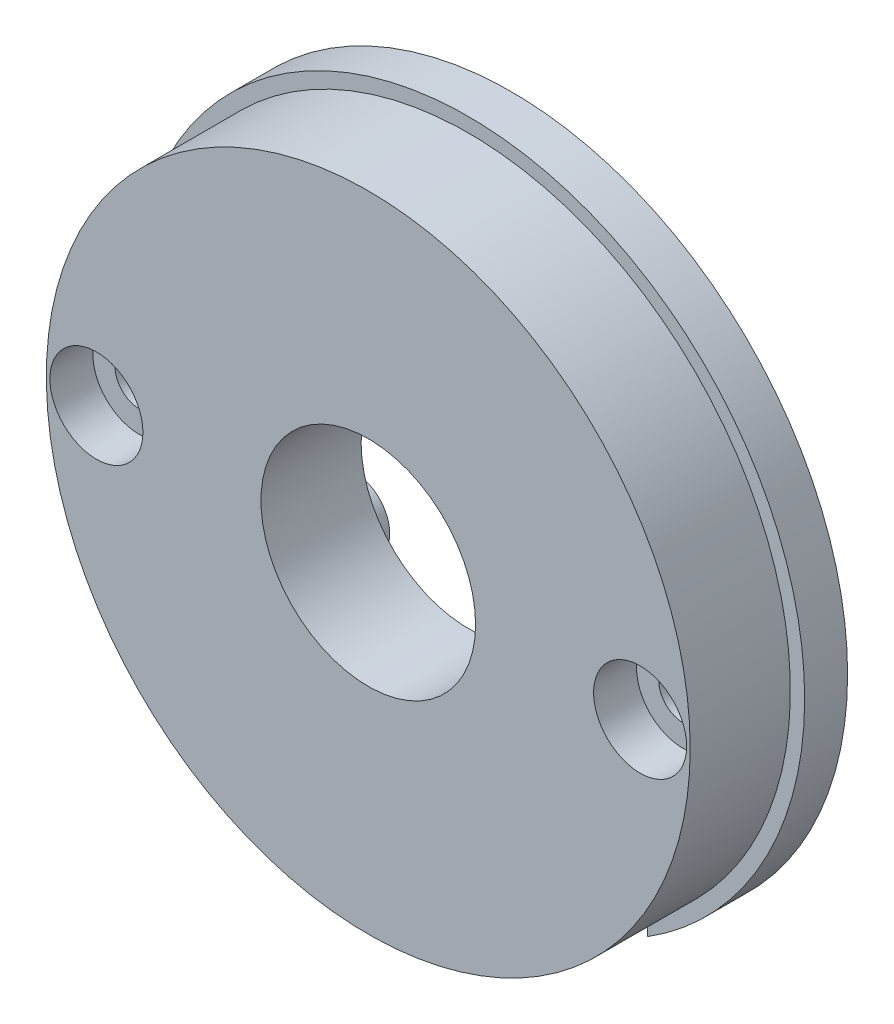
from build123d import *

# Parameters (mm, degrees)
SKETCH_5_R                   = 22.5
EXTRUDE_2_DEPTH              = 10
HOLE_WIZARD_M3_1_D           = 3.4
HOLE_WIZARD_M3_1_CBORE_D     = 6.5
HOLE_WIZARD_M3_1_CBORE_DEPTH = 3
SKETCH_12_W                  = 25
SKETCH_12_H                  = 40
CUT_EXTRUDE_1_DEPTH          = 3
EXTRUDE_3_DEPTH              = 1
SKETCH_14_R                  = 1.75
CUT_EXTRUDE_2_DEPTH          = 3
MIRROR_2_COPY_1_DEPTH        = 1
MIRROR_2_COPY_2_SKETCH_R     = 1.75
MIRROR_2_COPY_2_DEPTH        = 3
SKETCH_16_R                  = 7.5
CUT_EXTRUDE_3_DEPTH          = 11
EXTRUDE_4_DEPTH              = 3


with BuildPart() as part:
    # ｽｹｯﾁ5 → ﾎﾞｽ - 押し出し2 (new body)
    with BuildSketch(Plane.XY):
        Circle(SKETCH_5_R)
    extrude(amount=EXTRUDE_2_DEPTH)

    # M3 穴付きねじ用座ぐり穴1 (through all)
    with Locations(Plane.XY.offset(10)):
        with Locations((19, 0), (-19, 0)):
            CounterBoreHole(HOLE_WIZARD_M3_1_D / 2, HOLE_WIZARD_M3_1_CBORE_D / 2, HOLE_WIZARD_M3_1_CBORE_DEPTH)

    # ｽｹｯﾁ12 → ｶｯﾄ - 押し出し1 (cut)
    with BuildSketch(Plane(origin=(0, 0, 0), x_dir=(-1, 0, 0), z_dir=(0, 0, -1))):
        with Locations((0, -2.5)):
            Rectangle(SKETCH_12_W, SKETCH_12_H)
    extrude(amount=-CUT_EXTRUDE_1_DEPTH, mode=Mode.SUBTRACT)

    # ｽｹｯﾁ13 → ﾎﾞｽ - 押し出し3 (add)
    with BuildSketch(Plane(origin=(0, 0, 3), x_dir=(-1, 0, 0), z_dir=(0, 0, -1))):
        with BuildLine():
            Line((-12.5, 3), (-9, 3))
            ThreePointArc((-9, 3), (-6.5, 5.5), (-9, 8))
            Line((-9, 8), (-12.5, 8))
            Line((-12.5, 8), (-12.5, 3))
        make_face()
    extrude_3 = extrude(amount=EXTRUDE_3_DEPTH)

    # ｽｹｯﾁ14 → ｶｯﾄ - 押し出し2 (cut)
    with BuildSketch(Plane(origin=(0, 0, 2), x_dir=(-1, 0, 0), z_dir=(0, 0, -1))):
        with Locations((-9, 5.5)):
            Circle(SKETCH_14_R)
    cut_extrude_2 = extrude(amount=-CUT_EXTRUDE_2_DEPTH, mode=Mode.SUBTRACT)

    # ﾐﾗｰ1: ﾎﾞｽ - 押し出し3, ｶｯﾄ - 押し出し2 across plane
    add(extrude_3.mirror(Plane(origin=(0, 0, 0), x_dir=(0, 0, 1), z_dir=(1, 0, 0))))
    add(cut_extrude_2.mirror(Plane(origin=(0, 0, 0), x_dir=(0, 0, 1), z_dir=(1, 0, 0))), mode=Mode.SUBTRACT)

    # ﾐﾗｰ2: ﾎﾞｽ - 押し出し3, ｶｯﾄ - 押し出し2 across plane
    add(extrude_3.mirror(Plane.ZX))
    add(cut_extrude_2.mirror(Plane.ZX), mode=Mode.SUBTRACT)

    # ﾐﾗｰ2 copy 1 sketch → ﾐﾗｰ2 copy 1 (add)
    with BuildSketch(Plane(origin=(0, 0, 3), x_dir=(1, 0, 0), z_dir=(0, 0, -1))):
        with BuildLine():
            Line((-12.5, 3), (-9, 3))
            ThreePointArc((-9, 3), (-6.5, 5.5), (-9, 8))
            Line((-9, 8), (-12.5, 8))
            Line((-12.5, 8), (-12.5, 3))
        make_face()
    extrude(amount=MIRROR_2_COPY_1_DEPTH)

    # ﾐﾗｰ2 copy 2 sketch → ﾐﾗｰ2 copy 2 (cut)
    with BuildSketch(Plane(origin=(0, 0, 2), x_dir=(1, 0, 0), z_dir=(0, 0, -1))):
        with Locations((-9, 5.5)):
            Circle(MIRROR_2_COPY_2_SKETCH_R)
    extrude(amount=-MIRROR_2_COPY_2_DEPTH, mode=Mode.SUBTRACT)

    # ｽｹｯﾁ16 → ｶｯﾄ - 押し出し3 (cut, through all)
    with BuildSketch(Plane.XY.offset(10)):
        Circle(SKETCH_16_R)
    extrude(amount=-CUT_EXTRUDE_3_DEPTH, mode=Mode.SUBTRACT)

    # ｽｹｯﾁ17 → ﾎﾞｽ - 押し出し4 (add)
    with BuildSketch(Plane(origin=(0, 0, 0), x_dir=(-1, 0, 0), z_dir=(0, 0, -1))):
        with BuildLine():
            ThreePointArc((22.5, 0), (19.843134833, -10.606601718), (12.5, -18.708286934))
            Line((12.5, -18.708286934), (12.5, -19.899748742))
            ThreePointArc((12.5, -19.899748742), (20.566963801, -11.368817001), (23.5, 0))
            ThreePointArc((23.5, 0), (-11.368817001, 20.566963801), (-12.5, -19.899748742))
            Line((-12.5, -19.899748742), (-12.5, -18.708286934))
            ThreePointArc((-12.5, -18.708286934), (-10.606601718, 19.843134833), (22.5, 0))
        make_face()
    extrude(amount=-EXTRUDE_4_DEPTH)


solid = part.part
